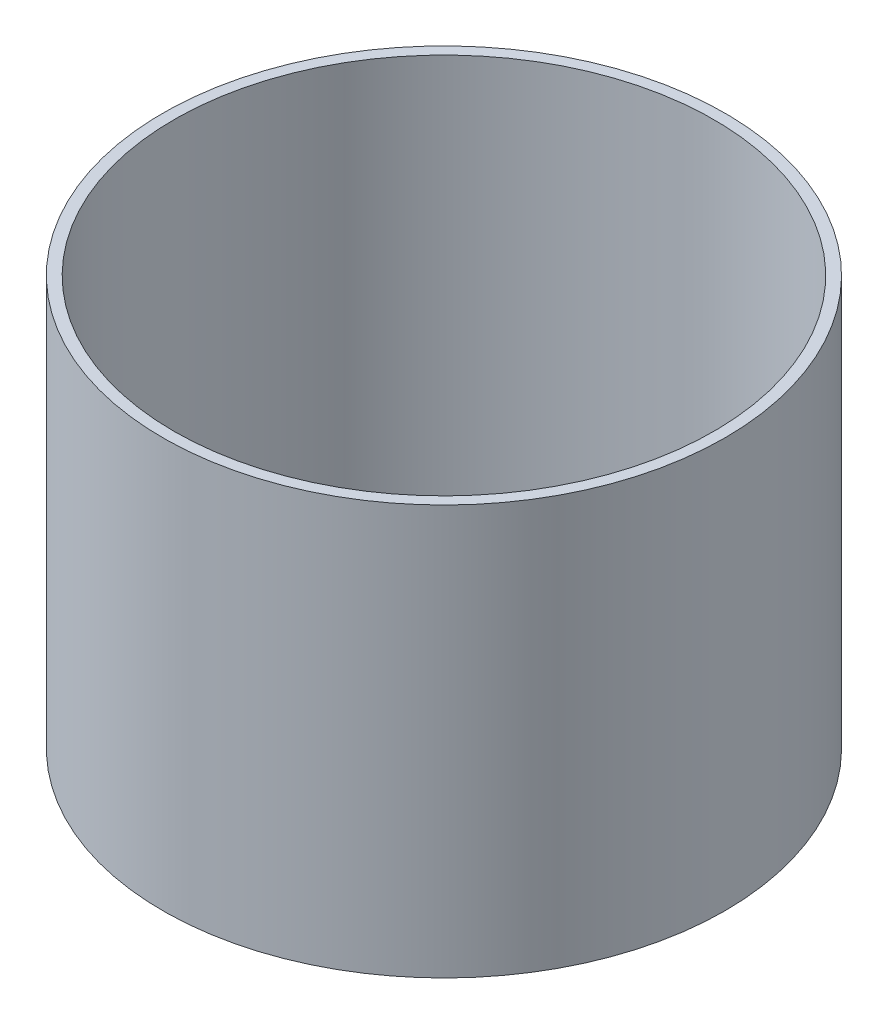
from build123d import *

# Parameters (mm, degrees)
SKETCH1_R           = 191.77
SKETCH1_R_2         = 184.15
EXTRUDE_THIN1_DEPTH = 279.4


with BuildPart() as part:
    # Sketch1 → Extrude-Thin1 (new body)
    with BuildSketch(Plane(origin=(0, 0, 0), x_dir=(1, 0, 0), z_dir=(0, 1, 0))):
        Circle(SKETCH1_R)
        Circle(SKETCH1_R_2, mode=Mode.SUBTRACT)
    extrude(amount=EXTRUDE_THIN1_DEPTH)


solid = part.part
